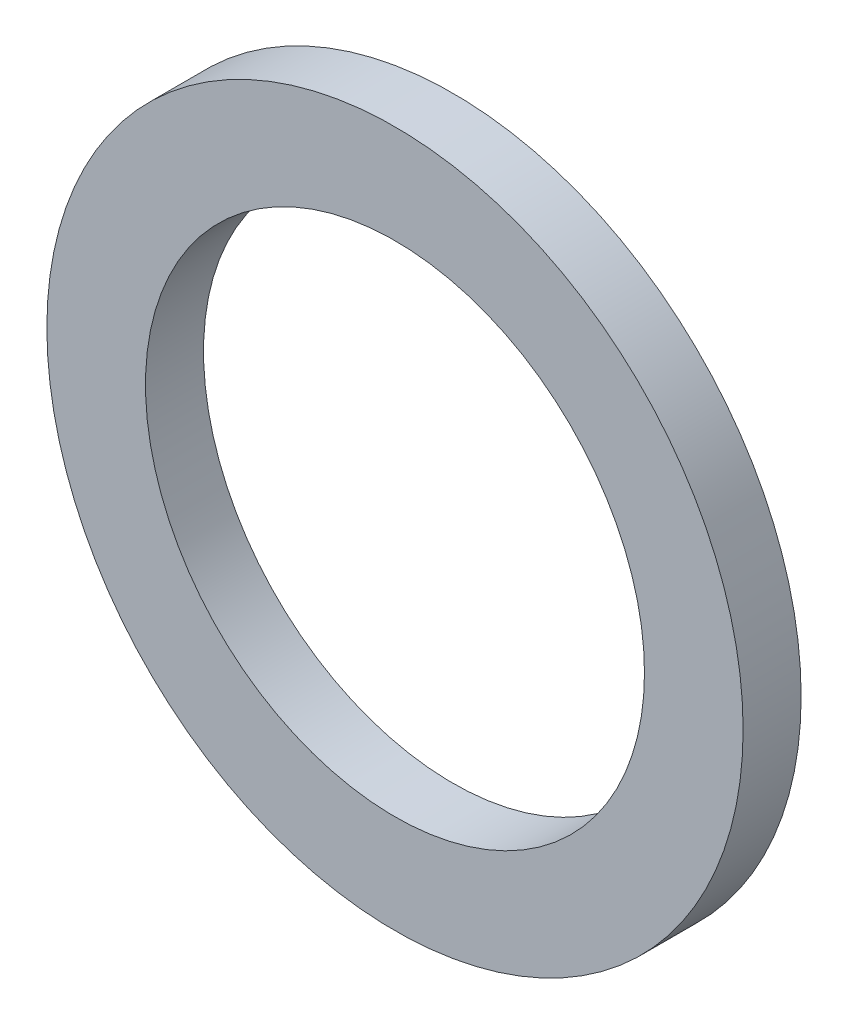
from build123d import *

# Parameters (mm, degrees)
SKETCH1_R           = 3
SKETCH1_R_2         = 2.15
BOSS_EXTRUDE1_DEPTH = 0.5


with BuildPart() as part:
    # Sketch1 → Boss-Extrude1 (new body)
    with BuildSketch(Plane.XY):
        Circle(SKETCH1_R)
        Circle(SKETCH1_R_2, mode=Mode.SUBTRACT)
    extrude(amount=BOSS_EXTRUDE1_DEPTH)


solid = part.part
